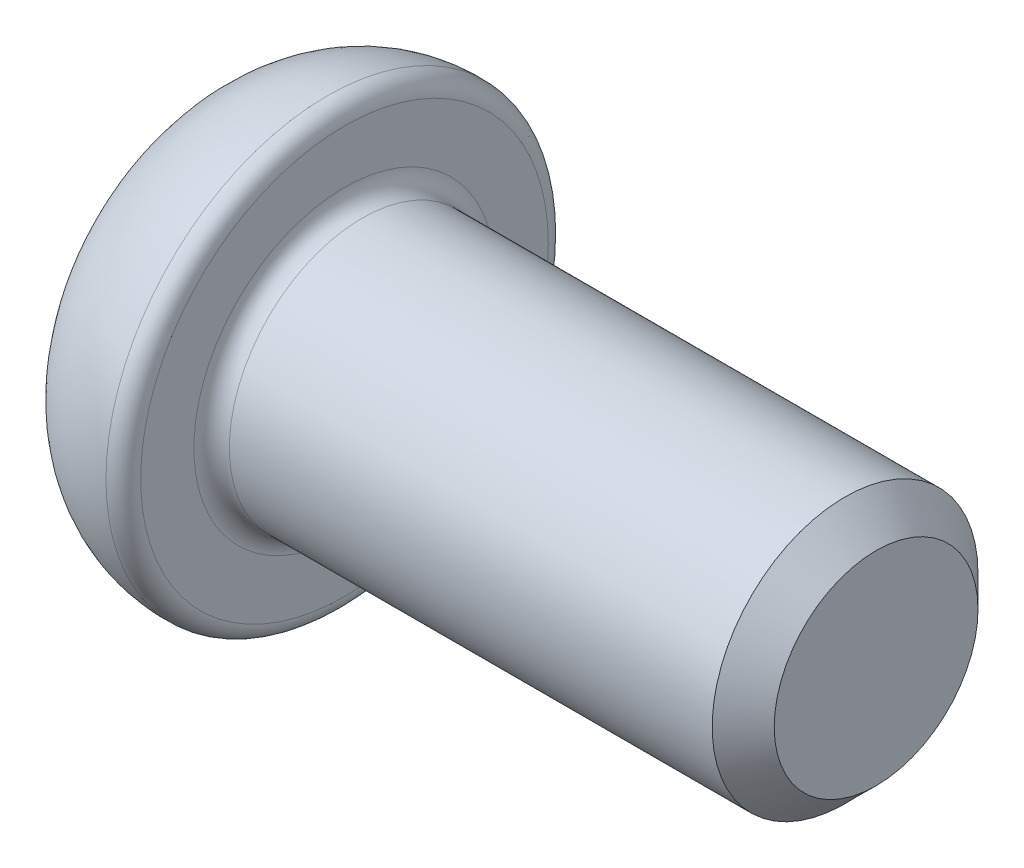
from build123d import *

# Parameters (mm, degrees)
CUT_EXTRUDE1_DEPTH = 0.9


with BuildPart() as part:
    # Sketch1 → Revolve1 (revolve)
    with BuildSketch(Plane.XY):
        with BuildLine():
            Line((0, 0), (0, 1.001109878))
            ThreePointArc((0, 1.001109878), (0.459937132, 2.081974916), (1.557692308, 2.5))
            ThreePointArc((1.557692308, 2.5), (1.694115338, 2.438823033), (1.75, 2.300147984))
            Line((1.75, 2.300147984), (1.75, 1.7))
            ThreePointArc((1.75, 1.7), (1.808578644, 1.558578644), (1.95, 1.5))
            Line((1.95, 1.5), (7.4, 1.5))
            Line((7.4, 1.5), (7.75, 1.15))
            Line((7.75, 1.15), (7.75, 0))
            Line((7.75, 0), (0, 0))
        make_face()
    revolve(axis=Axis((0, 0, 0), (-1, 0, 0)))

    # Sketch2 → Cut-Extrude1 (cut)
    with BuildSketch(Plane.ZY):
        Polygon((1, -0.577350269), (1, 0.577350269), (0, 1.154700538), (-1, 0.577350269), (-1, -0.577350269), (0, -1.154700538), align=None)
    extrude(amount=-CUT_EXTRUDE1_DEPTH, mode=Mode.SUBTRACT)


solid = part.part
